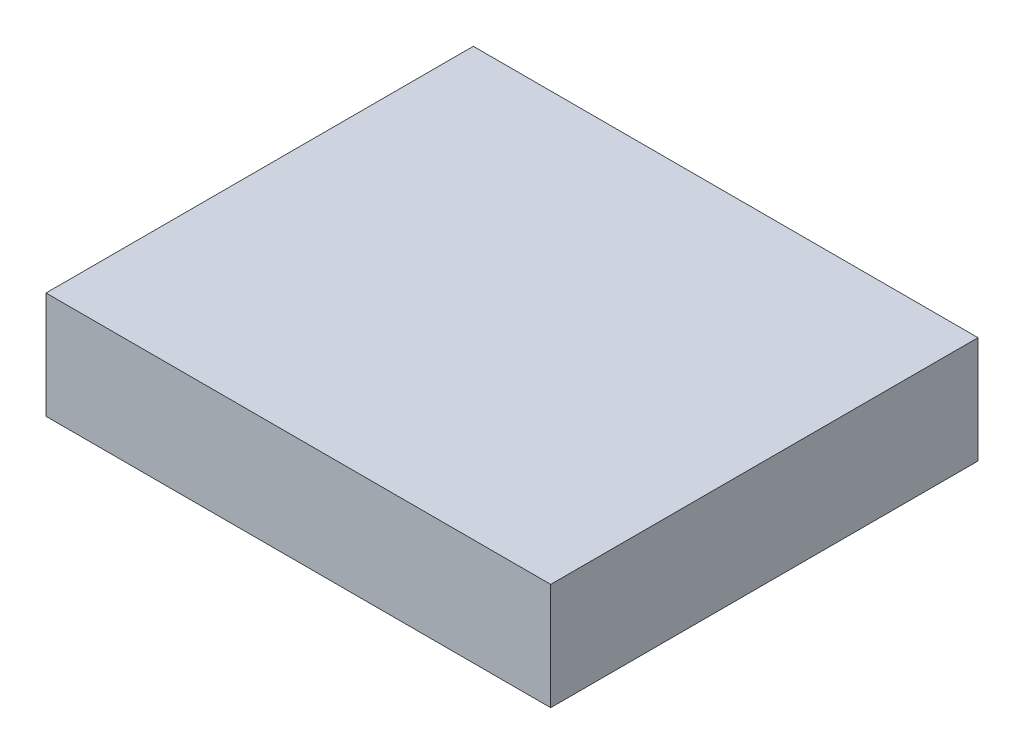
from build123d import *

# Parameters (mm, degrees)
SKETCH1_W           = 30
SKETCH1_H           = 25.4
BOSS_EXTRUDE1_DEPTH = 6.35


with BuildPart() as part:
    # Sketch1 → Boss-Extrude1 (new body)
    with BuildSketch(Plane(origin=(0, 0, 0), x_dir=(1, 0, 0), z_dir=(0, 1, 0))):
        with Locations((15, -12.7)):
            Rectangle(SKETCH1_W, SKETCH1_H)
    extrude(amount=-BOSS_EXTRUDE1_DEPTH)


solid = part.part
